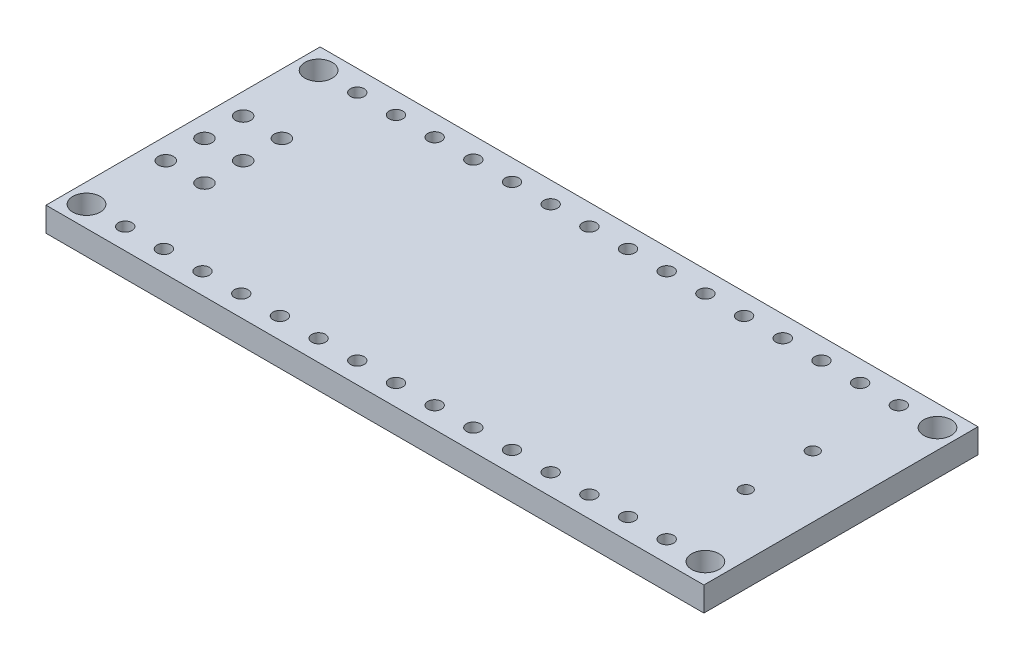
from build123d import *

# Parameters (mm, degrees)
SKETCH1_W           = 43.2
SKETCH1_H           = 18
BOSS_EXTRUDE2_DEPTH = 1.6
SKETCH2_R           = 0.45
CUT_EXTRUDE2_DEPTH  = 1.6
LPATTERN1_COUNT     = 15
LPATTERN1_PITCH     = 2.54
SKETCH3_R           = 0.5
CUT_EXTRUDE4_DEPTH  = 1.6
SKETCH4_R           = 0.9
CUT_EXTRUDE5_DEPTH  = 1.6
SKETCH9_R           = 0.4
CUT_EXTRUDE6_DEPTH  = 10


with BuildPart() as part:
    # Sketch1 → Boss-Extrude2 (new body)
    with BuildSketch(Plane(origin=(0, 0, 0), x_dir=(1, 0, 0), z_dir=(0, 1, 0))):
        with Locations((17.78, 7.62)):
            Rectangle(SKETCH1_W, SKETCH1_H)
    extrude(amount=BOSS_EXTRUDE2_DEPTH)

    # Sketch2 → Cut-Extrude2 (cut)
    with BuildSketch(Plane(origin=(0, 0, 0), x_dir=(1, 0, 0), z_dir=(0, 1, 0))):
        Circle(SKETCH2_R)
        with Locations((0, 15.24)):
            Circle(SKETCH2_R)
    cut_extrude2 = extrude(amount=CUT_EXTRUDE2_DEPTH, mode=Mode.SUBTRACT)

    # LPattern1: Cut-Extrude2 ×15
    with Locations(*[(i * LPATTERN1_PITCH, 0, 0) for i in range(1, LPATTERN1_COUNT)]):
        add(cut_extrude2, mode=Mode.SUBTRACT)

    # Sketch3 → Cut-Extrude4 (cut)
    with BuildSketch(Plane(origin=(0, 0, 0), x_dir=(1, 0, 0), z_dir=(0, 1, 0))):
        with Locations((0.127, 10.16)):
            Circle(SKETCH3_R)
        with Locations((-2.413, 10.16)):
            Circle(SKETCH3_R)
        with Locations((-2.413, 7.62)):
            Circle(SKETCH3_R)
        with Locations((-2.413, 5.08)):
            Circle(SKETCH3_R)
        with Locations((0.127, 5.08)):
            Circle(SKETCH3_R)
        with Locations((0.127, 7.62)):
            Circle(SKETCH3_R)
    extrude(amount=CUT_EXTRUDE4_DEPTH, mode=Mode.SUBTRACT)

    # Sketch4 → Cut-Extrude5 (cut)
    with BuildSketch(Plane(origin=(0, 0, 0), x_dir=(1, 0, 0), z_dir=(0, 1, 0))):
        with Locations((38.1, 15.24)):
            Circle(SKETCH4_R)
        with Locations((38.1, 0)):
            Circle(SKETCH4_R)
        with Locations((-2.54, 0)):
            Circle(SKETCH4_R)
        with Locations((-2.54, 15.24)):
            Circle(SKETCH4_R)
    extrude(amount=CUT_EXTRUDE5_DEPTH, mode=Mode.SUBTRACT)

    # Sketch9 → Cut-Extrude6 (cut)
    with BuildSketch(Plane(origin=(0, 0, 0), x_dir=(1, 0, 0), z_dir=(0, 1, 0))):
        with Locations((35.33, 5.42)):
            Circle(SKETCH9_R)
        with Locations((35.33, 9.82)):
            Circle(SKETCH9_R)
    extrude(amount=CUT_EXTRUDE6_DEPTH, mode=Mode.SUBTRACT)


solid = part.part
